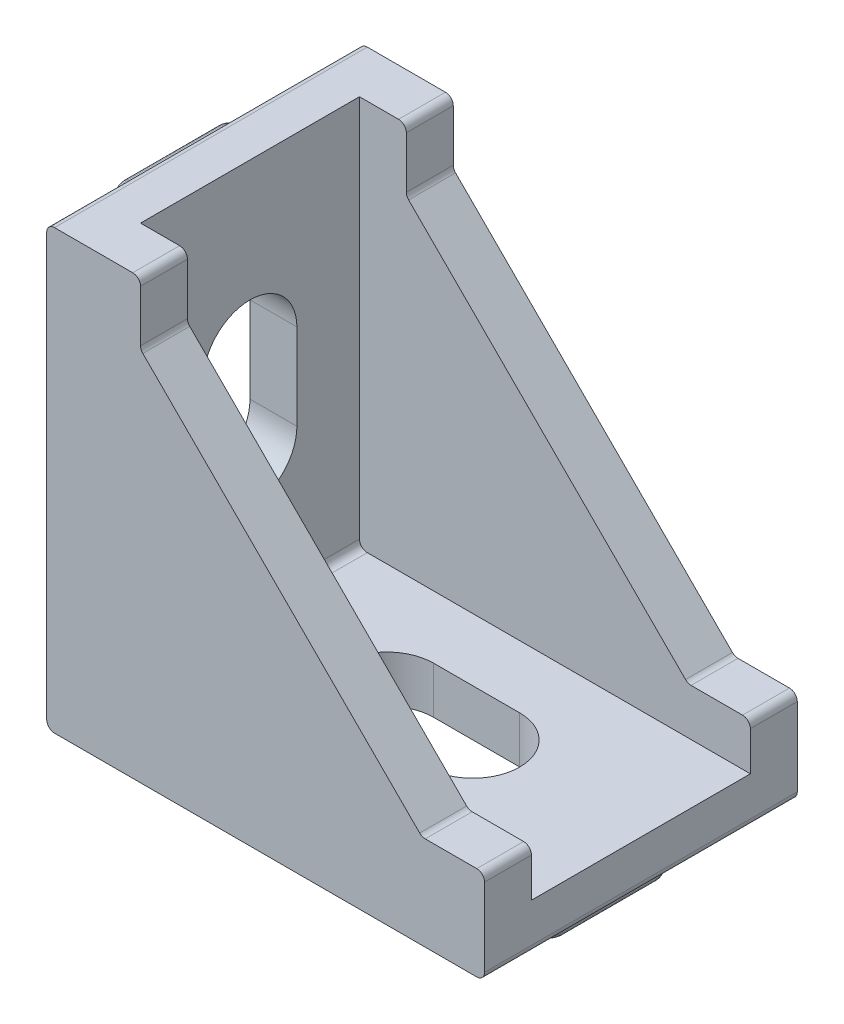
from build123d import *

# Parameters (mm, degrees)
BOSS_EXTRUDE1_DEPTH = 20
SKETCH2_W           = 25
SKETCH2_H           = 14
CUT_EXTRUDE1_DEPTH  = 25
CUT_EXTRUDE2_DEPTH  = 29
BOSS_EXTRUDE2_DEPTH = 2
FILLET4_R           = 0.5
FILLET5_R           = 0.2


with BuildPart() as part:
    # Sketch1 → Boss-Extrude1 (new body)
    with BuildSketch(Plane.XY):
        Polygon((-8, 10), (-8, 14), (-14, 14), (-14, -14), (14, -14), (14, -8), (10, -8), align=None)
    extrude(amount=BOSS_EXTRUDE1_DEPTH)

    # Sketch2 → Cut-Extrude1 (cut)
    with BuildSketch(Plane(origin=(0, 14, 0), x_dir=(1, 0, 0), z_dir=(0, 1, 0))):
        with Locations((1.5, -10)):
            Rectangle(SKETCH2_W, SKETCH2_H)
    extrude(amount=-CUT_EXTRUDE1_DEPTH, mode=Mode.SUBTRACT)

    # Sketch3 → Cut-Extrude2 (cut, through all)
    with BuildSketch(Plane.XZ.offset(14)):
        with BuildLine():
            Line((-2.25, 13), (3.25, 13))
            ThreePointArc((3.25, 13), (6.25, 10), (3.25, 7))
            Line((3.25, 7), (-2.25, 7))
            ThreePointArc((-2.25, 7), (-5.25, 10), (-2.25, 13))
        make_face()
    cut_extrude2 = extrude(amount=-CUT_EXTRUDE2_DEPTH, mode=Mode.SUBTRACT)

    # Mirror1: Cut-Extrude2 across plane
    add(cut_extrude2.mirror(Plane(origin=(0, 0, 0), x_dir=(0, 0, 1), z_dir=(-0.707106781, 0.707106781, 0))), mode=Mode.SUBTRACT)

    # Sketch4 → Boss-Extrude2 (add)
    with BuildSketch(Plane.ZY.offset(14)):
        with BuildLine():
            Line((7, 12), (13, 12))
            ThreePointArc((13, 12), (14, 11), (13, 10))
            Line((13, 10), (7, 10))
            ThreePointArc((7, 10), (6, 11), (7, 12))
        make_face()
        with BuildLine():
            Line((7, -12), (13, -12))
            ThreePointArc((13, -12), (14, -11), (13, -10))
            Line((13, -10), (7, -10))
            ThreePointArc((7, -10), (6, -11), (7, -12))
        make_face()
    boss_extrude2 = extrude(amount=BOSS_EXTRUDE2_DEPTH)

    # Mirror4: Boss-Extrude2 across plane
    add(boss_extrude2.mirror(Plane(origin=(0, 0, 0), x_dir=(0, 0, 1), z_dir=(-0.707106781, 0.707106781, 0))))

    # Fillet4
    fillet4_edges = [part.edges().sort_by_distance(p)[0] for p in [
        (14, -8, 18.5),
        (14, -14, 10),
        (-14, -14, 10),
        (-14, 14, 10),
        (-8, 14, 18.5),
        (-8, 10, 18.5),
        (10, -8, 18.5),
        (14, -8, 1.5),
        (-8, 14, 1.5),
        (-8, 10, 1.5),
        (10, -8, 1.5),
        (-11, -11, 10),
    ]]
    fillet(fillet4_edges, radius=FILLET4_R)

    # Fillet5
    fillet5_edges = [part.edges().sort_by_distance(p)[0] for p in [
        (-16, -11, 6),
        (-16, -12, 10),
        (-16, -11, 14),
        (-16, -10, 10),
        (11, -16, 6),
        (12, -16, 10),
        (11, -16, 14),
        (10, -16, 10),
        (-11, -16, 6),
        (-10, -16, 10),
        (-11, -16, 14),
        (-12, -16, 10),
        (-16, 11, 6),
        (-16, 10, 10),
        (-16, 11, 14),
        (-16, 12, 10),
    ]]
    fillet(fillet5_edges, radius=FILLET5_R)


solid = part.part
